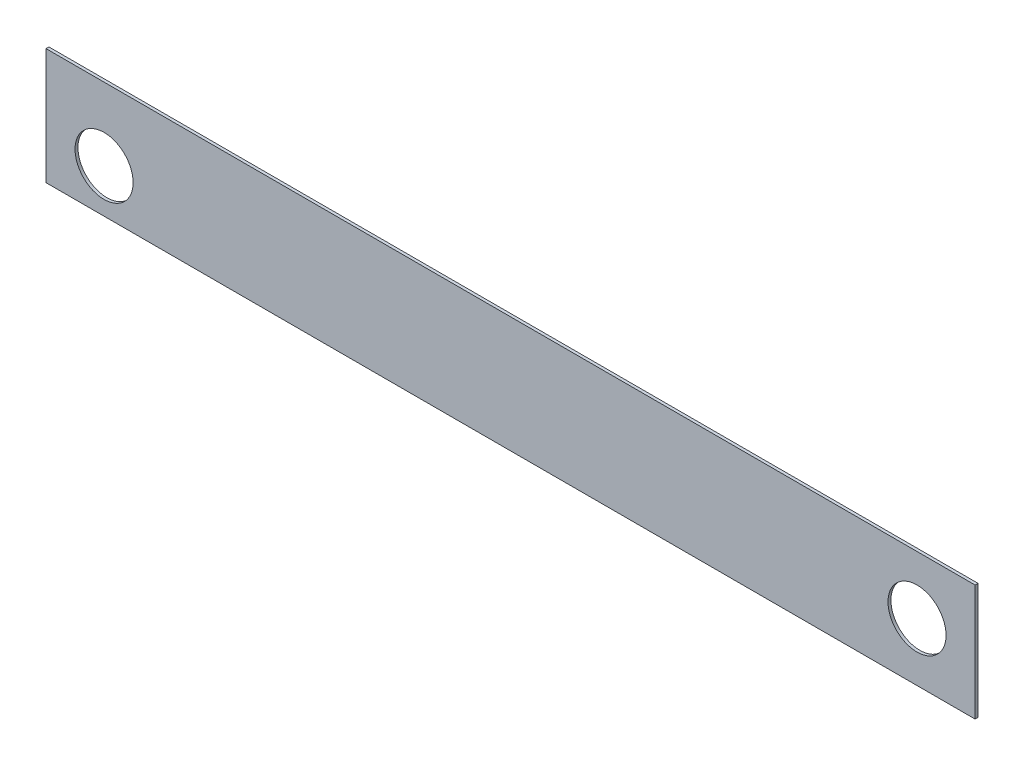
from build123d import *

# Parameters (mm, degrees)
SKETCH1_W      = 320
SKETCH1_H      = 40
SKETCH1_R      = 10
EXTRUDE1_DEPTH = 1


with BuildPart() as part:
    # Sketch1 → Extrude1 (new body)
    with BuildSketch(Plane.XY):
        with Locations((140, 5)):
            Rectangle(SKETCH1_W, SKETCH1_H)
        Circle(SKETCH1_R, mode=Mode.SUBTRACT)
        with Locations((280, 5)):
            Circle(SKETCH1_R, mode=Mode.SUBTRACT)
    extrude(amount=EXTRUDE1_DEPTH)


solid = part.part
